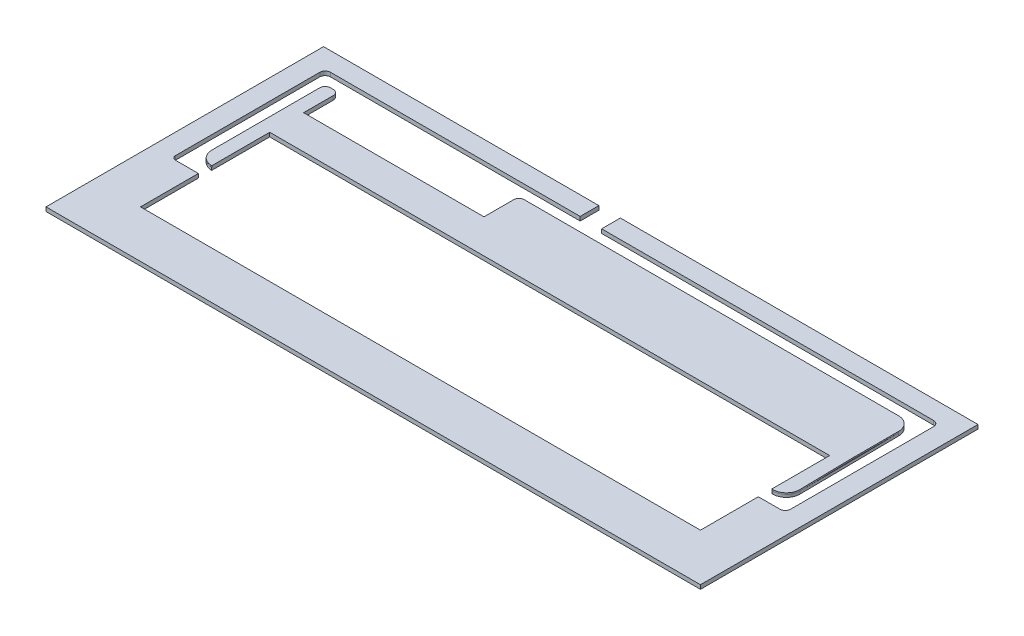
from build123d import *

# Parameters (mm, degrees)
CROQUIS1_W              = 486.2
CROQUIS1_H              = 206.2
CROQUIS1_W_2            = 480
CROQUIS1_H_2            = 200
SALIENTE_EXTRUIR1_DEPTH = 12
CROQUIS3_W              = 486.2
CROQUIS3_H              = 206.2
CROQUIS3_W_2            = 480
CROQUIS3_H_2            = 200
CORTAR_EXTRUIR1_DEPTH   = 5
CORTAR_EXTRUIR3_DEPTH   = 8
CROQUIS4_W              = 20
CROQUIS4_H              = 6
CORTAR_EXTRUIR4_DEPTH   = 3
CORTAR_EXTRUIR5_DEPTH   = 2
CROQUIS7_W              = 721.947089947
CROQUIS7_H              = 359.419856831
CORTAR_EXTRUIR6_DEPTH   = 10
CROQUIS8_W              = 416
CROQUIS8_H              = 96
CORTAR_EXTRUIR7_DEPTH   = 10
CROQUIS9_W              = 531.904745737
CROQUIS9_H              = 246.353411826
CORTAR_EXTRUIR9_DEPTH   = 10
CROQUIS10_W             = 531.904745737
CROQUIS10_H             = 246.353411826
CORTAR_EXTRUIR10_DEPTH  = 10
CROQUIS11_W             = 531.904745737
CROQUIS11_H             = 246.353411826
CORTAR_EXTRUIR11_DEPTH  = 10


with BuildPart() as part:
    # Croquis1 → Saliente-Extruir1 (new body)
    with BuildSketch(Plane(origin=(0, 0, 0), x_dir=(1, 0, 0), z_dir=(0, 1, 0))):
        with Locations((240, 100)):
            Rectangle(CROQUIS1_W, CROQUIS1_H)
        with Locations((240, 100)):
            Rectangle(CROQUIS1_W_2, CROQUIS1_H_2, mode=Mode.SUBTRACT)
        with Locations((240, 100)):
            Rectangle(CROQUIS1_W_2, CROQUIS1_H_2)
    extrude(amount=SALIENTE_EXTRUIR1_DEPTH)

    # Croquis3 → Cortar-Extruir1 (cut)
    with BuildSketch(Plane(origin=(0, 12, 0), x_dir=(1, 0, 0), z_dir=(0, 1, 0))):
        with Locations((240, 100)):
            Rectangle(CROQUIS3_W, CROQUIS3_H)
        with Locations((240, 100)):
            Rectangle(CROQUIS3_W_2, CROQUIS3_H_2, mode=Mode.SUBTRACT)
    extrude(amount=-CORTAR_EXTRUIR1_DEPTH, mode=Mode.SUBTRACT)

    # Croquis2 → Cortar-Extruir3 (cut)
    with BuildSketch(Plane(origin=(0, 12, 0), x_dir=(1, 0, 0), z_dir=(0, 1, 0))):
        with BuildLine():
            ThreePointArc((16, 189.1902066), (13.171572875, 188.018633725), (12, 185.1902066))
            Line((12, 185.1902066), (12, 78))
            ThreePointArc((12, 78), (12.878679656, 75.878679656), (15, 75))
            Line((15, 75), (32, 75))
            Line((32, 75), (32, 32))
            Line((32, 32), (448, 32))
            Line((448, 32), (448, 75))
            Line((448, 75), (464, 75))
            ThreePointArc((464, 75), (466.828427125, 76.171572875), (468, 79))
            Line((468, 79), (468, 185.1902066))
            ThreePointArc((468, 185.1902066), (466.828427125, 188.018633725), (464, 189.1902066))
            Line((464, 189.1902066), (217.424703227, 189.1902066))
            Line((217.424703227, 189.1902066), (217.424703227, 203.1))
            Line((217.424703227, 203.1), (201.44869327, 203.1))
            Line((201.44869327, 203.1), (201.44869327, 189.1902066))
            Line((201.44869327, 189.1902066), (16, 189.1902066))
        make_face()
        with BuildLine():
            Line((32, 85), (31.963588191, 85))
            ThreePointArc((31.963588191, 85), (24.892520379, 87.928932188), (21.963588191, 95))
            Line((21.963588191, 95), (21.963588191, 175.1902066))
            ThreePointArc((21.963588191, 175.1902066), (23.135161066, 178.018633725), (25.963588191, 179.1902066))
            Line((25.963588191, 179.1902066), (28, 179.1902066))
            ThreePointArc((28, 179.1902066), (30.828427125, 178.018633725), (32, 175.1902066))
            Line((32, 175.1902066), (32, 153.1902066))
            Line((32, 153.1902066), (166, 153.1902066))
            Line((166, 153.1902066), (166, 175.1902066))
            ThreePointArc((166, 175.1902066), (167.171572875, 178.018633725), (170, 179.1902066))
            Line((170, 179.1902066), (448.036411809, 179.1902066))
            ThreePointArc((448.036411809, 179.1902066), (455.107479621, 176.261274412), (458.036411809, 169.1902066))
            Line((458.036411809, 169.1902066), (458.036411809, 135.000000034))
            Line((458.036411809, 135.000000034), (458.803569043, 95.19268186))
            ThreePointArc((458.803569043, 95.19268186), (455.944291637, 87.997386866), (448.80542553, 85))
            Line((448.80542553, 85), (448, 85))
            Line((448, 85), (448, 128))
            Line((448, 128), (32, 128))
            Line((32, 128), (32, 85))
        make_face(mode=Mode.SUBTRACT)
    extrude(amount=-CORTAR_EXTRUIR3_DEPTH, mode=Mode.SUBTRACT)

    # Croquis4 → Cortar-Extruir4 (cut)
    with BuildSketch(Plane(origin=(0, 12, 0), x_dir=(1, 0, 0), z_dir=(0, 1, 0))):
        with BuildLine():
            Line((31.963588191, 85), (32, 128))
            Line((32, 128), (32, 134))
            Line((32, 134), (32, 147.1902066))
            Line((32, 147.1902066), (32, 153.1902066))
            Line((32, 153.1902066), (32, 175.1902066))
            ThreePointArc((32, 175.1902066), (30.828427125, 178.018633725), (28, 179.1902066))
            Line((28, 179.1902066), (25.963588191, 179.1902066))
            ThreePointArc((25.963588191, 179.1902066), (23.135161066, 178.018633725), (21.963588191, 175.1902066))
            Line((21.963588191, 175.1902066), (21.963588191, 95))
            ThreePointArc((21.963588191, 95), (24.892520379, 87.928932188), (31.963588191, 85))
        make_face()
        with Locations((42, 131)):
            Rectangle(CROQUIS4_W, CROQUIS4_H)
        with Locations((42, 150.1902066)):
            Rectangle(CROQUIS4_W, CROQUIS4_H)
        with BuildLine():
            ThreePointArc((12, 78), (12.878679656, 75.878679656), (15, 75))
            Line((15, 75), (32, 75))
            Line((32, 75), (32, 69))
            Line((32, 69), (6, 69))
            Line((6, 69), (6, 80))
            Line((6, 80), (6, 195.1902066))
            Line((6, 195.1902066), (16, 195.1902066))
            Line((16, 195.1902066), (32, 195.1902066))
            Line((32, 195.1902066), (32, 189.1902066))
            Line((32, 189.1902066), (16, 189.1902066))
            ThreePointArc((16, 189.1902066), (13.171572875, 188.018633725), (12, 185.1902066))
            Line((12, 185.1902066), (12, 80))
            Line((12, 80), (12, 78))
        make_face()
        with Locations((42, 192.1902066)):
            Rectangle(CROQUIS4_W, CROQUIS4_H)
        with Locations((42, 29)):
            Rectangle(CROQUIS4_W, CROQUIS4_H)
        with Locations((156, 192.1902066)):
            Rectangle(CROQUIS4_W, CROQUIS4_H)
        with Locations((156, 150.1902066)):
            Rectangle(CROQUIS4_W, CROQUIS4_H)
        with BuildLine():
            Line((166, 147.1902066), (448, 147.1902066))
            Line((448, 147.1902066), (458.036411809, 147.1902066))
            Line((458.036411809, 147.1902066), (458.036411809, 169.1902066))
            ThreePointArc((458.036411809, 169.1902066), (455.107479621, 176.261274412), (448.036411809, 179.1902066))
            Line((448.036411809, 179.1902066), (170, 179.1902066))
            ThreePointArc((170, 179.1902066), (167.171572875, 178.018633725), (166, 175.1902066))
            Line((166, 175.1902066), (166, 153.1902066))
            Line((166, 153.1902066), (166, 147.1902066))
        make_face()
        with BuildLine():
            Line((458.036411809, 169.1902066), (458.036411809, 147.1902066))
            Line((458.036411809, 147.1902066), (474, 147.1902066))
            Line((474, 147.1902066), (474, 195.1902066))
            Line((474, 195.1902066), (166, 195.1902066))
            Line((166, 195.1902066), (166, 189.1902066))
            Line((166, 189.1902066), (166, 175.1902066))
            ThreePointArc((166, 175.1902066), (167.171572875, 178.018633725), (170, 179.1902066))
            Line((170, 179.1902066), (448.036411809, 179.1902066))
            ThreePointArc((448.036411809, 179.1902066), (455.107479621, 176.261274412), (458.036411809, 169.1902066))
        make_face()
        with BuildLine():
            Line((448.80542553, 85), (448, 85))
            Line((448, 85), (448, 69))
            Line((448, 69), (474, 69))
            Line((474, 69), (474, 147.1902066))
            Line((474, 147.1902066), (458.036411809, 147.1902066))
            Line((458.036411809, 147.1902066), (458.036411809, 135.000000034))
            Line((458.036411809, 135.000000034), (458.803569043, 95.19268186))
            ThreePointArc((458.803569043, 95.19268186), (455.944291637, 87.997386866), (448.80542553, 85))
        make_face()
        with Locations((438, 131)):
            Rectangle(CROQUIS4_W, CROQUIS4_H)
        with Locations((438, 29)):
            Rectangle(CROQUIS4_W, CROQUIS4_H)
        with BuildLine():
            Line((448, 134), (448, 128))
            Line((448, 128), (448, 85))
            Line((448, 85), (448.80542553, 85))
            ThreePointArc((448.80542553, 85), (455.944291637, 87.997386866), (458.803569043, 95.19268186))
            Line((458.803569043, 95.19268186), (458.036411809, 135.000000034))
            Line((458.036411809, 135.000000034), (458.036411809, 147.1902066))
            Line((458.036411809, 147.1902066), (448, 147.1902066))
            Line((448, 147.1902066), (448, 134))
        make_face()
    extrude(amount=-CORTAR_EXTRUIR4_DEPTH, mode=Mode.SUBTRACT)

    # Croquis5 → Cortar-Extruir5 (cut)
    with BuildSketch(Plane(origin=(0, 4, 0), x_dir=(1, 0, 0), z_dir=(0, 1, 0))):
        with BuildLine():
            Line((32.046028397, 84.926485337), (32, 75))
            Line((32, 75), (15, 75))
            ThreePointArc((15, 75), (12.878679656, 75.878679656), (12, 78))
            Line((12, 78), (12, 185.1902066))
            ThreePointArc((12, 185.1902066), (13.171572875, 188.018633725), (16, 189.1902066))
            Line((16, 189.1902066), (201.44869327, 189.1902066))
            Line((201.44869327, 189.1902066), (201.44869327, 203.1))
            Line((201.44869327, 203.1), (217.424703227, 203.1))
            Line((217.424703227, 203.1), (217.424703227, 189.1902066))
            Line((217.424703227, 189.1902066), (464, 189.1902066))
            ThreePointArc((464, 189.1902066), (466.828427125, 188.018633725), (468, 185.1902066))
            Line((468, 185.1902066), (468, 79))
            ThreePointArc((468, 79), (466.828427125, 76.171572875), (464, 75))
            Line((464, 75), (448, 75))
            Line((448, 75), (448, 85))
            Line((448, 85), (448.80542553, 85))
            ThreePointArc((448.80542553, 85), (455.917657262, 88.023512896), (458.803569043, 95.19268186))
            Line((458.803569043, 95.19268186), (458.036411809, 169.1902066))
            ThreePointArc((458.036411809, 169.1902066), (455.107479621, 176.261274412), (448.036411809, 179.1902066))
            Line((448.036411809, 179.1902066), (170, 179.1902066))
            ThreePointArc((170, 179.1902066), (167.171572875, 178.018633725), (166, 175.1902066))
            Line((166, 175.1902066), (166, 153.1902066))
            Line((166, 153.1902066), (32, 153.1902066))
            Line((32, 153.1902066), (32, 175.1902066))
            ThreePointArc((32, 175.1902066), (30.828427125, 178.018633725), (28, 179.1902066))
            Line((28, 179.1902066), (25.963588191, 179.1902066))
            ThreePointArc((25.963588191, 179.1902066), (23.135161066, 178.018633725), (21.963588191, 175.1902066))
            Line((21.963588191, 175.1902066), (21.963588191, 95))
            ThreePointArc((21.963588191, 95), (24.91720844, 87.873793117), (32.046028397, 84.926485337))
        make_face()
    extrude(amount=-CORTAR_EXTRUIR5_DEPTH, mode=Mode.SUBTRACT)

    # Croquis7 → Cortar-Extruir6 (cut)
    with BuildSketch(Plane(origin=(0, 2, 0), x_dir=(1, 0, 0), z_dir=(0, 1, 0))):
        with Locations((149.368191722, 161.470369199)):
            Rectangle(CROQUIS7_W, CROQUIS7_H)
    extrude(amount=-CORTAR_EXTRUIR6_DEPTH, mode=Mode.SUBTRACT)

    # Croquis8 → Cortar-Extruir7 (cut)
    with BuildSketch(Plane(origin=(0, 4, 0), x_dir=(1, 0, 0), z_dir=(0, 1, 0))):
        with Locations((240, 80)):
            Rectangle(CROQUIS8_W, CROQUIS8_H)
    extrude(amount=-CORTAR_EXTRUIR7_DEPTH, mode=Mode.SUBTRACT)


with BuildPart() as cortar_extruir7_piece_1:
    # of the separate pieces the step leaves, piece 1, a body of its own (cortar_extruir7_pieces)
    add(part.part.solids().sort_by_distance((483.1, 2, 3.1))[0])


with BuildPart() as cortar_extruir7_piece_2:
    # of the separate pieces the step leaves, piece 2, a body of its own (cortar_extruir7_pieces)
    add(part.part.solids().sort_by_distance((32, 2, -128))[0])


with BuildPart() as cortar_extruir9_tool:
    # Croquis9 → Cortar-Extruir9 (new body)
    with BuildSketch(Plane(origin=(0, 9, 0), x_dir=(1, 0, 0), z_dir=(0, 1, 0))):
        with Locations((247.004349215, 106.418772052)):
            Rectangle(CROQUIS9_W, CROQUIS9_H)
    extrude(amount=CORTAR_EXTRUIR9_DEPTH)


with BuildPart() as cortar_extruir7_piece_1_1:
    add(cortar_extruir7_piece_1.part)

    # Cortar-Extruir9: cut by cortar_extruir9_tool
    add(cortar_extruir9_tool.part, mode=Mode.SUBTRACT)


with BuildPart() as cortar_extruir7_piece_2_1:
    add(cortar_extruir7_piece_2.part)

    # Cortar-Extruir9: cut by cortar_extruir9_tool
    add(cortar_extruir9_tool.part, mode=Mode.SUBTRACT)


with BuildPart() as cortar_extruir10_tool:
    # Croquis10 → Cortar-Extruir10 (new body)
    with BuildSketch(Plane(origin=(0, 7, 0), x_dir=(1, 0, 0), z_dir=(0, 1, 0))):
        with Locations((247.004349215, 106.418772052)):
            Rectangle(CROQUIS10_W, CROQUIS10_H)
    extrude(amount=CORTAR_EXTRUIR10_DEPTH)


with BuildPart() as cortar_extruir7_piece_1_2:
    add(cortar_extruir7_piece_1_1.part)

    # Cortar-Extruir10: cut by cortar_extruir10_tool
    add(cortar_extruir10_tool.part, mode=Mode.SUBTRACT)


with BuildPart() as cortar_extruir7_piece_2_2:
    add(cortar_extruir7_piece_2_1.part)

    # Cortar-Extruir10: cut by cortar_extruir10_tool
    add(cortar_extruir10_tool.part, mode=Mode.SUBTRACT)


with BuildPart() as cortar_extruir11_tool:
    # Croquis11 → Cortar-Extruir11 (new body)
    with BuildSketch(Plane(origin=(0, 5, 0), x_dir=(-1, 0, 0), z_dir=(0, -1, 0))):
        with Locations((-247.004349215, 106.418772052)):
            Rectangle(CROQUIS11_W, CROQUIS11_H)
    extrude(amount=-CORTAR_EXTRUIR11_DEPTH)


with BuildPart() as cortar_extruir7_piece_1_3:
    add(cortar_extruir7_piece_1_2.part)

    # Cortar-Extruir11: cut by cortar_extruir11_tool
    add(cortar_extruir11_tool.part, mode=Mode.SUBTRACT)


with BuildPart() as cortar_extruir7_piece_2_3:
    add(cortar_extruir7_piece_2_2.part)

    # Cortar-Extruir11: cut by cortar_extruir11_tool
    add(cortar_extruir11_tool.part, mode=Mode.SUBTRACT)


solid = Compound([cortar_extruir7_piece_1_3.part, cortar_extruir7_piece_2_3.part])
